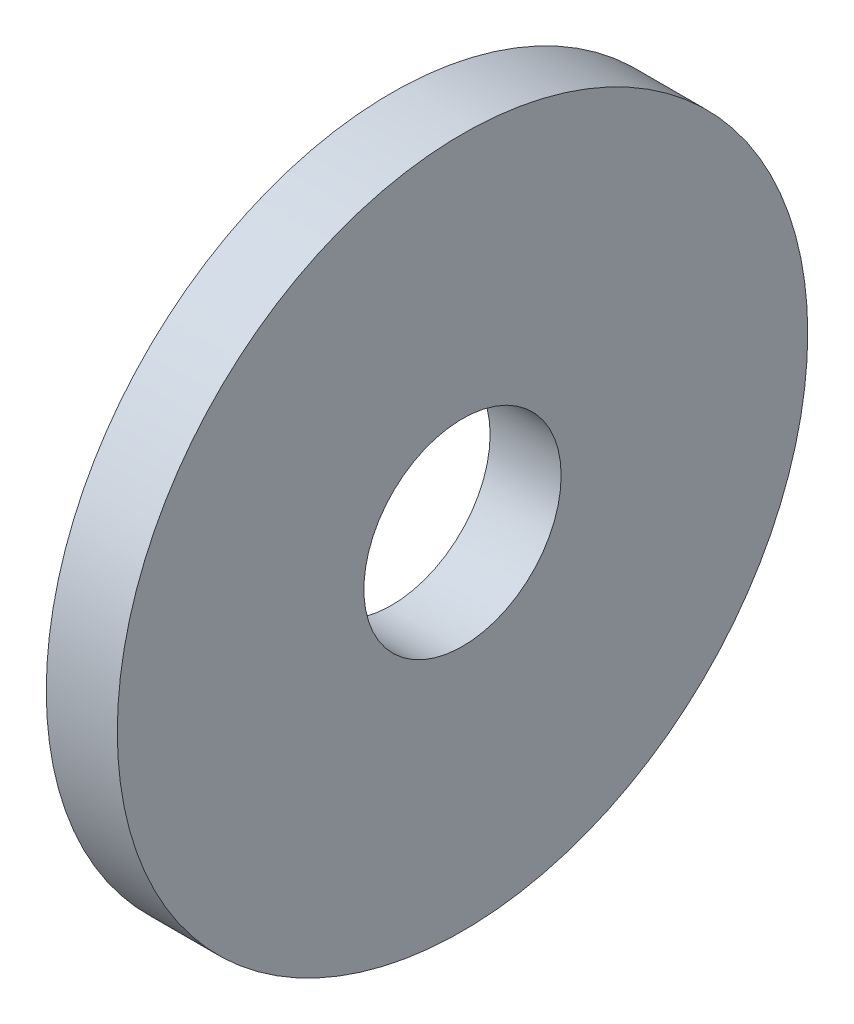
from build123d import *

# Parameters (mm, degrees)
SKETCH1_R           = 5.55625
SKETCH1_R_2         = 1.5875
BOSS_EXTRUDE1_DEPTH = 1.143


with BuildPart() as part:
    # Sketch1 → Boss-Extrude1 (new body)
    with BuildSketch(Plane(origin=(0, 0, 0), x_dir=(0, 0, -1), z_dir=(1, 0, 0))):
        Circle(SKETCH1_R)
        Circle(SKETCH1_R_2, mode=Mode.SUBTRACT)
    extrude(amount=BOSS_EXTRUDE1_DEPTH)


solid = part.part
